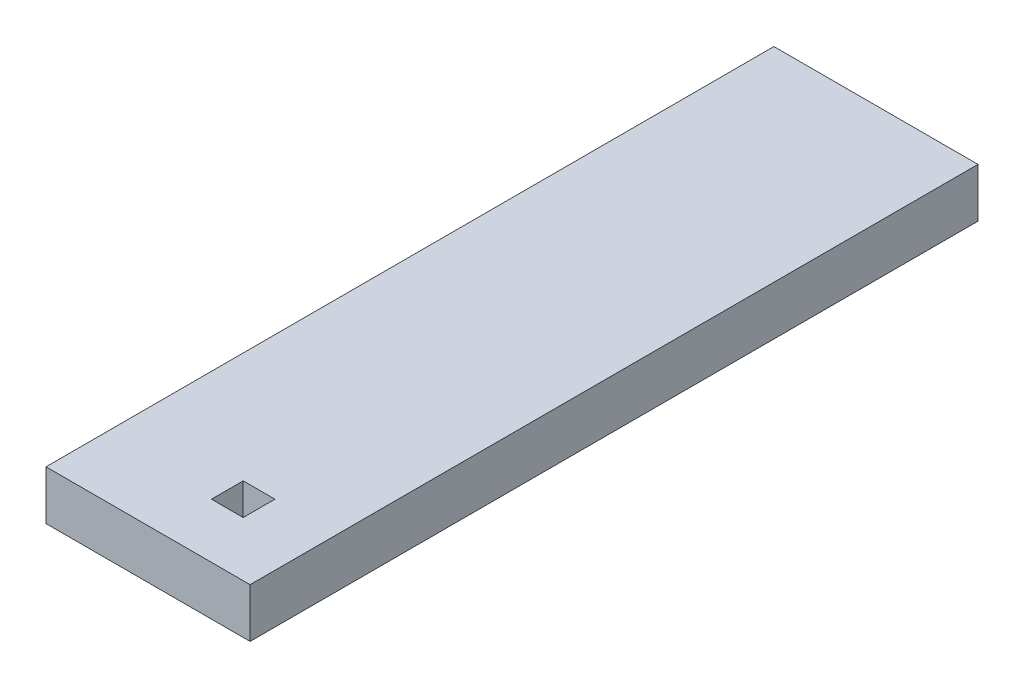
from build123d import *

# Parameters (mm, degrees)
SKETCH1_W           = 10
SKETCH1_H           = 46.99
SKETCH1_W_2         = 2.049999964
SKETCH1_H_2         = 2.049999964
BOSS_EXTRUDE1_DEPTH = 3.175
SKETCH2_W           = 3.175
SKETCH2_H           = 46.99
BOSS_EXTRUDE2_DEPTH = 3.175


with BuildPart() as part:
    # Sketch1 → Boss-Extrude1 (new body)
    with BuildSketch(Plane(origin=(0, 0, 0), x_dir=(1, 0, 0), z_dir=(0, 1, 0))):
        Rectangle(SKETCH1_W, SKETCH1_H)
        with Locations((0, -18.939243554)):
            Rectangle(SKETCH1_W_2, SKETCH1_H_2, mode=Mode.SUBTRACT)
    extrude(amount=BOSS_EXTRUDE1_DEPTH)

    # Sketch2 → Boss-Extrude2 (add)
    with BuildSketch(Plane(origin=(0, 3.175, 0), x_dir=(1, 0, 0), z_dir=(0, 1, 0))):
        with Locations((-6.5875, 0)):
            Rectangle(SKETCH2_W, SKETCH2_H)
    extrude(amount=-BOSS_EXTRUDE2_DEPTH)


solid = part.part
